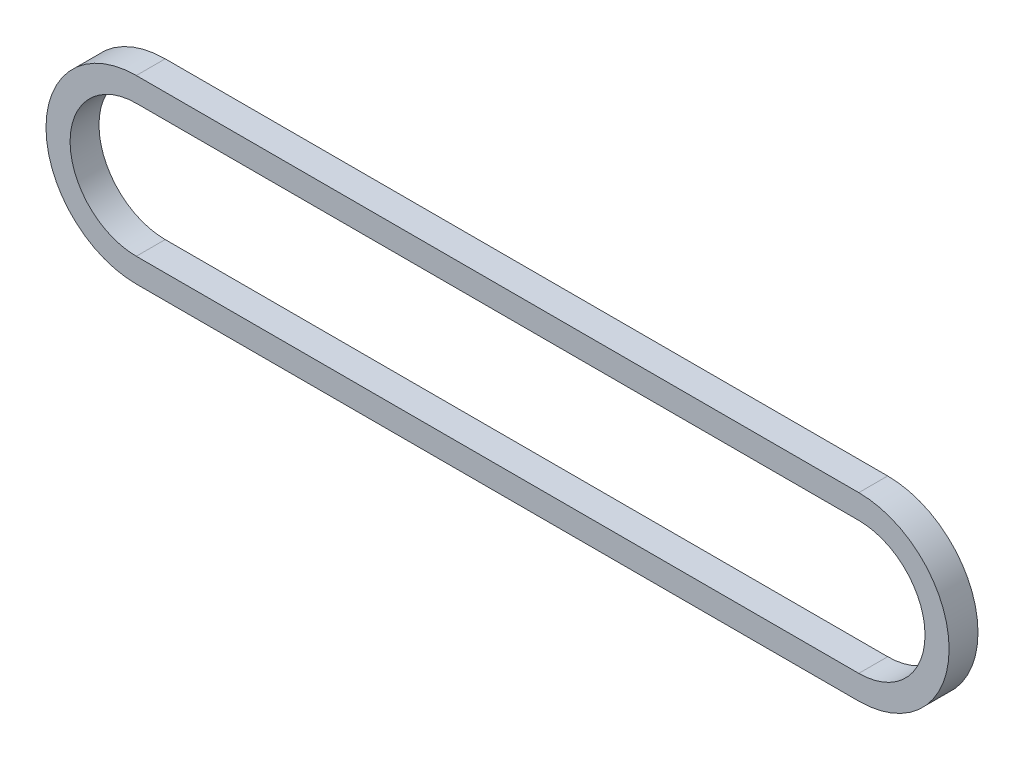
from build123d import *

# Parameters (mm, degrees)
RESSALTO_EXTRUS_O1_DEPTH = 6


with BuildPart() as part:
    # Esboço1 → Ressalto-extrusão1 (new body, symmetric)
    with BuildSketch(Plane.XY):
        with BuildLine():
            Line((-150, 37.5), (150, 37.5))
            ThreePointArc((150, 37.5), (187.5, 0), (150, -37.5))
            Line((150, -37.5), (-150, -37.5))
            ThreePointArc((-150, -37.5), (-187.5, 0), (-150, 37.5))
        make_face()
        with BuildLine():
            Line((-150, 27.5), (150, 27.5))
            ThreePointArc((150, 27.5), (177.5, 0), (150, -27.5))
            Line((150, -27.5), (-150, -27.5))
            ThreePointArc((-150, -27.5), (-177.5, 0), (-150, 27.5))
        make_face(mode=Mode.SUBTRACT)
    extrude(amount=RESSALTO_EXTRUS_O1_DEPTH, both=True)


solid = part.part
